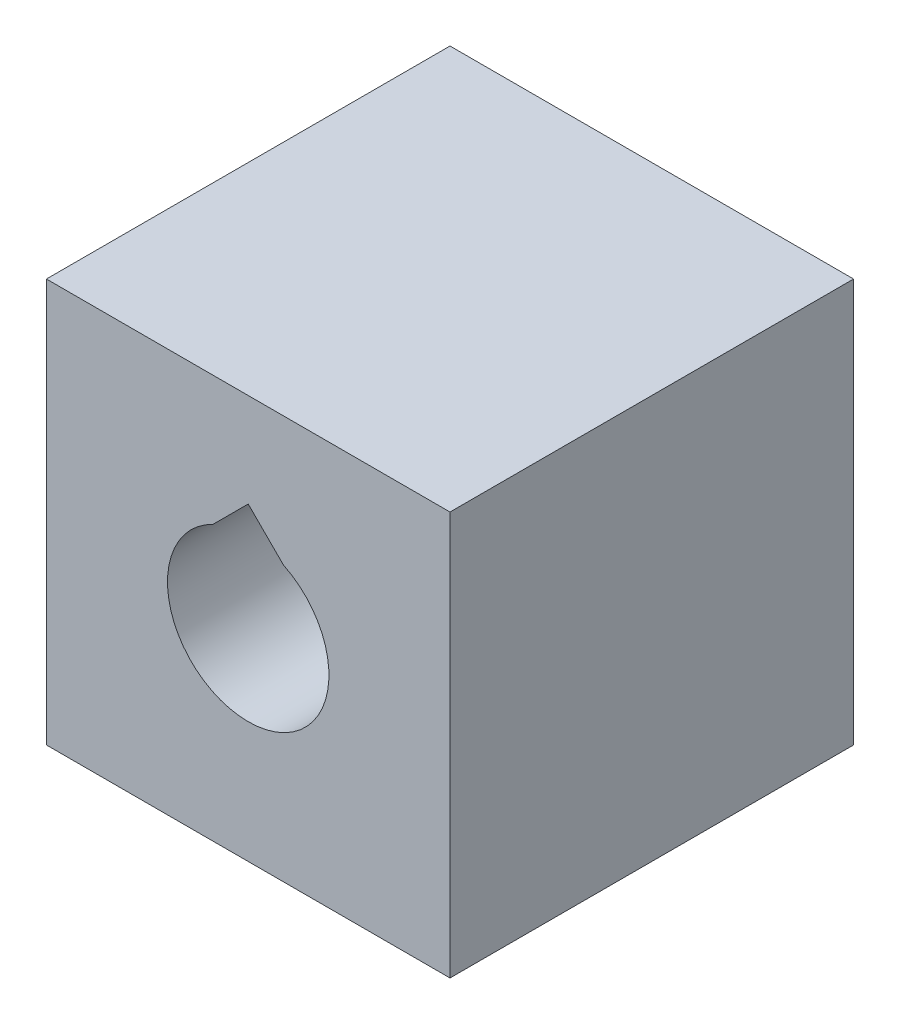
from build123d import *

# Parameters (mm, degrees)
SKETCH1_W           = 25
SKETCH1_H           = 25
BOSS_EXTRUDE1_DEPTH = 25
CUT_EXTRUDE1_DEPTH  = 26


with BuildPart() as part:
    # Sketch1 → Boss-Extrude1 (new body)
    with BuildSketch(Plane(origin=(0, 0, 0), x_dir=(1, 0, 0), z_dir=(0, 1, 0))):
        Rectangle(SKETCH1_W, SKETCH1_H)
    extrude(amount=BOSS_EXTRUDE1_DEPTH)

    # Sketch2 → Cut-Extrude1 (cut, through all)
    with BuildSketch(Plane.XY.offset(12.5)):
        with BuildLine():
            Line((-2.179449472, 17), (0, 19.179449472))
            Line((0, 19.179449472), (2.179449472, 17))
            ThreePointArc((2.179449472, 17), (0, 7.5), (-2.179449472, 17))
        make_face()
    extrude(amount=-CUT_EXTRUDE1_DEPTH, mode=Mode.SUBTRACT)


solid = part.part
